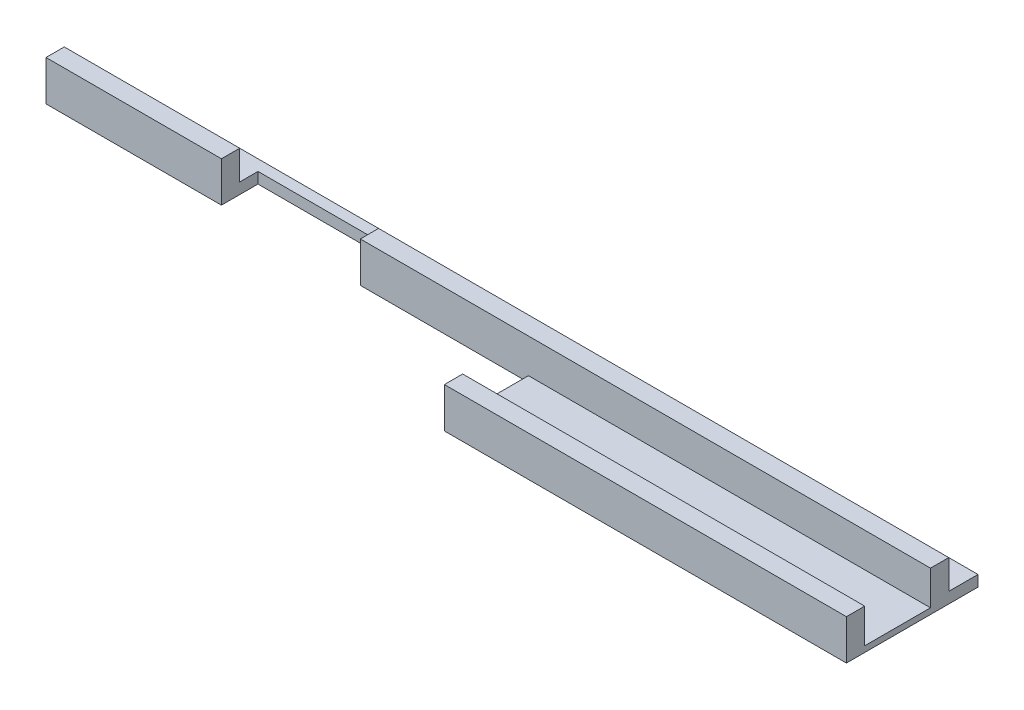
from build123d import *

# Parameters (mm, degrees)
SKETCH1_W               = 120
SKETCH1_H               = 137
BOSS_EXTRUDE1_DEPTH     = 3
SKETCH2_W               = 120
SKETCH2_H               = 5
BOSS_EXTRUDE2_DEPTH     = 8
SKETCH3_W               = 38
SKETCH3_H               = 10
CUT_EXTRUDE1_DEPTH      = 25
SKETCH4_W               = 120
SKETCH4_H               = 124
CUT_EXTRUDE2_DEPTH      = 92.412526494
CUT_EXTRUDE2_DEPTH_BACK = 92.412526494
BOSS_EXTRUDE3_DEPTH     = 7
BOSS_EXTRUDE4_DEPTH     = 120
SKETCH9_W               = 5
SKETCH9_H               = 23
CUT_EXTRUDE3_DEPTH      = 250
MOVE_FACE1_BY           = 5


with BuildPart() as part:
    # Sketch1 → Boss-Extrude1 (new body)
    with BuildSketch(Plane(origin=(0, 0, 0), x_dir=(1, 0, 0), z_dir=(0, 1, 0))):
        Rectangle(SKETCH1_W, SKETCH1_H)
    extrude(amount=BOSS_EXTRUDE1_DEPTH)

    # Sketch2 → Boss-Extrude2 (add)
    with BuildSketch(Plane(origin=(0, 3, 0), x_dir=(1, 0, 0), z_dir=(0, 1, 0))):
        with Locations((0, -66)):
            Rectangle(SKETCH2_W, SKETCH2_H)
    extrude(amount=BOSS_EXTRUDE2_DEPTH)

    # Sketch3 → Cut-Extrude1 (cut)
    with BuildSketch(Plane(origin=(0, 11, 0), x_dir=(1, 0, 0), z_dir=(0, 1, 0))):
        with Locations((0, -63.5)):
            Rectangle(SKETCH3_W, SKETCH3_H)
    extrude(amount=-CUT_EXTRUDE1_DEPTH, mode=Mode.SUBTRACT)

    # Sketch4 → Cut-Extrude2 (cut, two sides)
    with BuildSketch(Plane(origin=(0, 3, 0), x_dir=(1, 0, 0), z_dir=(0, 1, 0))) as cut_extrude2_sk:
        with Locations((0, 6.5)):
            Rectangle(SKETCH4_W, SKETCH4_H)
    extrude(amount=CUT_EXTRUDE2_DEPTH, mode=Mode.SUBTRACT)
    extrude(cut_extrude2_sk.sketch, amount=-CUT_EXTRUDE2_DEPTH_BACK, mode=Mode.SUBTRACT)

    # Sketch7 → Boss-Extrude3 (add)
    with BuildSketch(Plane.ZY.offset(60)):
        Polygon((63.5, 11), (63.5, 3), (55.5, 3), (55.5, 0), (68.5, 0), (68.5, 11), align=None)
    extrude(amount=BOSS_EXTRUDE3_DEPTH)

    # Sketch8 → Boss-Extrude4 (add)
    with BuildSketch(Plane(origin=(60, 0, 0), x_dir=(0, 0, -1), z_dir=(1, 0, 0))):
        Polygon((-55.5, 0), (-55.5, 3), (-63.5, 3), (-63.5, 11), (-68.5, 11), (-68.5, 1.6), (-86.5, 1.6), (-86.5, 11), (-91.5, 11), (-91.5, 0), align=None)
    extrude(amount=BOSS_EXTRUDE4_DEPTH)

    # Sketch9 → Cut-Extrude3 (cut)
    with BuildSketch(Plane(origin=(0, 11, 0), x_dir=(1, 0, 0), z_dir=(0, 1, 0))):
        with Locations((62.5, -80)):
            Rectangle(SKETCH9_W, SKETCH9_H)
    extrude(amount=-CUT_EXTRUDE3_DEPTH, mode=Mode.SUBTRACT)

    # Move Face1: a face moved inward by 5.0
    extrude(part.faces().sort_by_distance((180, 1.1, 73.5))[0], amount=MOVE_FACE1_BY, dir=(-1, 0, 0), mode=Mode.SUBTRACT)


solid = part.part
